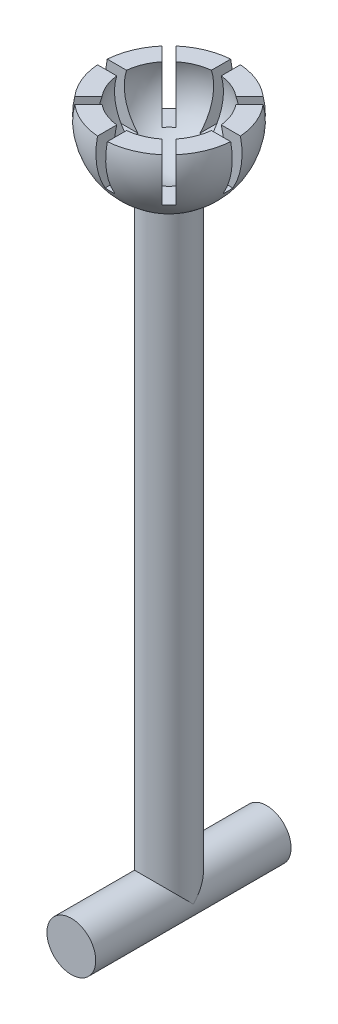
from build123d import *

# Parameters (mm, degrees)
ESQUISSE4_W                  = 1
ESQUISSE4_H                  = 15
ENL_V_MAT_EXTRU_2_DEPTH      = 5
R_P_TITION_CIRCULAIRE1_COUNT = 4
R_P_TITION_CIRCULAIRE1_ANGLE = 135
ESQUISSE5_R                  = 2.5
BOSS_EXTRU_1_DEPTH           = 57
ESQUISSE6_R                  = 2.5
BOSS_EXTRU_2_DEPTH           = 10


with BuildPart() as part:
    # Esquisse1 → R_volution1 (revolve)
    with BuildSketch(Plane.XY, mode=Mode.PRIVATE) as r_volution1_sk:
        with BuildLine():
            Line((-4.874423043, 1.5), (-6.837397166, 1.5))
            ThreePointArc((-6.837397166, 1.5), (-6.160398345, -3.324077651), (-2.5, -6.538348415))
            Line((-2.5, -6.538348415), (-2.5, -11.538348415))
            Line((-2.5, -11.538348415), (0, -11.538348415))
            Line((0, -11.538348415), (0, -5.1))
            ThreePointArc((0, -5.1), (-4.102438299, -3.029851482), (-4.874423043, 1.5))
        make_face()
    revolve(r_volution1_sk.sketch.rotate(Axis((0, -11.538348415, 0), (0, 1, 0)), 270), axis=Axis((0, -11.538348415, 0), (0, 1, 0)))  # turned: the seam where the file's is

    # Esquisse4 → Enl_v. mat.-Extru.2 (cut)
    with BuildSketch(Plane(origin=(0, 1.5, 0), x_dir=(1, 0, 0), z_dir=(0, 1, 0))):
        Rectangle(ESQUISSE4_W, ESQUISSE4_H)
    enl_v_mat_extru_2 = extrude(amount=-ENL_V_MAT_EXTRU_2_DEPTH, mode=Mode.SUBTRACT)

    # R_p_tition circulaire1: Enl_v. mat.-Extru.2 ×4 about axis
    r_p_tition_circulaire1_axis = Axis((0, 0, 0), (0, -1, 0))
    for i in range(1, R_P_TITION_CIRCULAIRE1_COUNT):
        add(enl_v_mat_extru_2.rotate(r_p_tition_circulaire1_axis, i * R_P_TITION_CIRCULAIRE1_ANGLE / (R_P_TITION_CIRCULAIRE1_COUNT - 1)), mode=Mode.SUBTRACT)

    # Esquisse5 → Boss.-Extru.1 (add)
    with BuildSketch(Plane.XZ.offset(11.538348415)):
        with Locations(Location((0, 0, 0), (0, 0, 270))):  # turned: the seam where the file's is
            Circle(ESQUISSE5_R)
    extrude(amount=BOSS_EXTRU_1_DEPTH)

    # Esquisse6 → Boss.-Extru.2 (add, symmetric)
    with BuildSketch(Plane.XY):
        with Locations((0, -68.538348415)):
            Circle(ESQUISSE6_R)
    extrude(amount=BOSS_EXTRU_2_DEPTH, both=True)


solid = part.part
